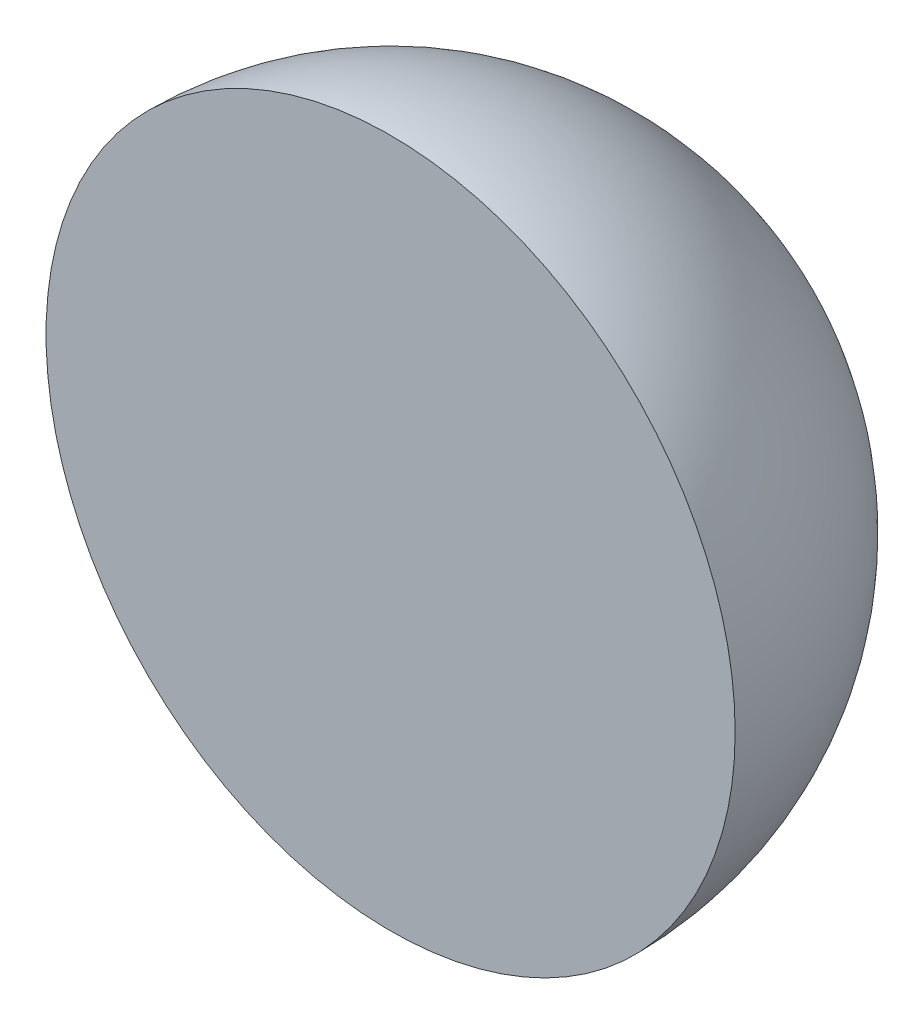
from build123d import *


with BuildPart() as part:
    # Sketch1 → Revolve1 (revolve)
    with BuildSketch(Plane(origin=(0, 0, 0), x_dir=(1, 0, 0), z_dir=(0, 1, 0))):
        with BuildLine():
            Line((0, 0), (31.5, 0))
            ThreePointArc((31.5, 0), (22.273863607, 22.273863607), (0, 31.5))
            Line((0, 31.5), (0, 0))
        make_face()
    revolve(axis=Axis((0, 0, 0), (0, 0, -1)))


solid = part.part
